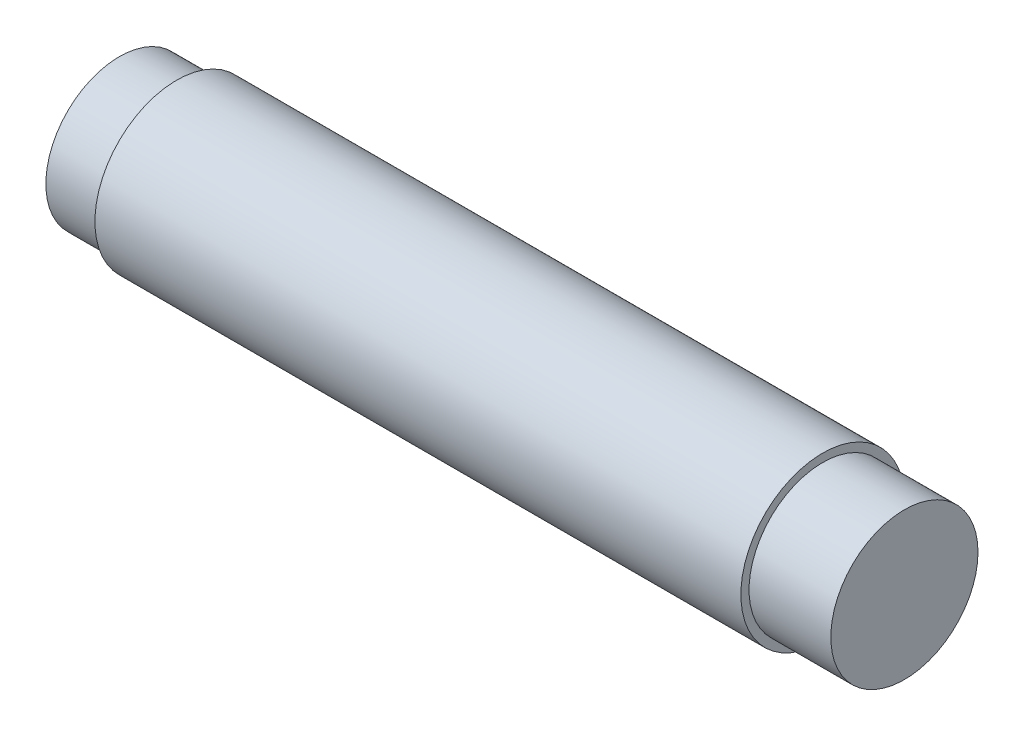
from build123d import *

# Parameters (mm, degrees)
SKETCH1_R                = 5
BOSS_EXTRUDE1_DEPTH      = 19
BOSS_EXTRUDE1_DEPTH_BACK = 20.5
SKETCH2_R                = 4.5
BOSS_EXTRUDE2_DEPTH      = 5


with BuildPart() as part:
    # Sketch1 → Boss-Extrude1 (new body, two sides)
    with BuildSketch(Plane(origin=(0, 0, 0), x_dir=(0, 0, -1), z_dir=(1, 0, 0))) as boss_extrude1_sk:
        Circle(SKETCH1_R)
    extrude(amount=BOSS_EXTRUDE1_DEPTH)
    extrude(boss_extrude1_sk.sketch, amount=-BOSS_EXTRUDE1_DEPTH_BACK)

    # Sketch2 → Boss-Extrude2 (add)
    with BuildSketch(Plane(origin=(19, 0, 0), x_dir=(0, 0, -1), z_dir=(1, 0, 0))):
        Circle(SKETCH2_R)
    boss_extrude2 = extrude(amount=BOSS_EXTRUDE2_DEPTH)

    # Mirror1: Boss-Extrude2 across plane
    add(boss_extrude2.mirror(Plane(origin=(0, 0, 0), x_dir=(0, 0, 1), z_dir=(1, 0, 0))))


solid = part.part
